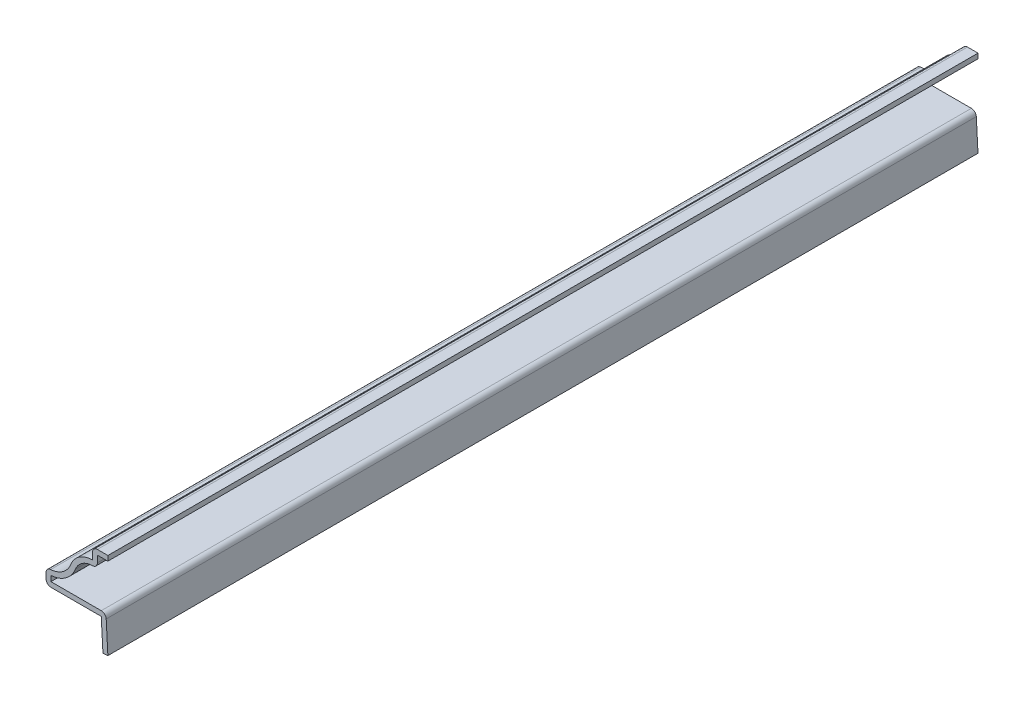
from build123d import *

# Parameters (mm, degrees)
EXTRUDE_THIN1_DEPTH = 178.59375
FILLET1_R           = 1.016


with BuildPart() as part:
    # Sketch1 → Extrude-Thin1 (new body)
    with BuildSketch(Plane.XY):
        with BuildLine():
            Line((0, 17.859375), (-3.175, 17.859375))
            Line((-3.175, 17.859375), (-3.175, 15.478125))
            ThreePointArc((-3.175, 15.478125), (-5.84807115, 14.657210579), (-7.599625174, 12.477470145))
            ThreePointArc((-7.599625174, 12.477470145), (-9.638294165, 10.117590004), (-12.7, 9.525))
            Line((-12.7, 9.525), (-12.7, 6.35))
            Line((-12.7, 6.35), (-1.359217172, 6.35))
            Line((-1.359217172, 6.35), (-1.014506285, 0))
            Line((-1.014506285, 0), (0, 0.055072655))
            Line((0, 0.055072655), (-0.396875, 7.366))
            Line((-0.396875, 7.366), (-11.684, 7.366))
            Line((-11.684, 7.366), (-11.684, 8.47084132))
            ThreePointArc((-11.684, 8.47084132), (-8.641469435, 9.554461447), (-6.655705137, 12.101609848))
            ThreePointArc((-6.655705137, 12.101609848), (-4.833592242, 14.074990123), (-2.159, 14.3217318))
            Line((-2.159, 14.3217318), (-2.159, 16.843375))
            Line((-2.159, 16.843375), (0, 16.843375))
            Line((0, 16.843375), (0, 17.859375))
        make_face()
    extrude(amount=-EXTRUDE_THIN1_DEPTH)

    # Fillet1
    fillet1_edges = [part.edges().sort_by_distance(p)[0] for p in [
        (-12.7, 6.35, -89.296875),
        (-12.7, 9.525, -89.296875),
        (-3.175, 17.859375, -89.296875),
        (-2.159, 14.3217318, -89.296875),
        (-0.396875, 7.366, -89.296875),
    ]]
    fillet(fillet1_edges, radius=FILLET1_R)


solid = part.part
